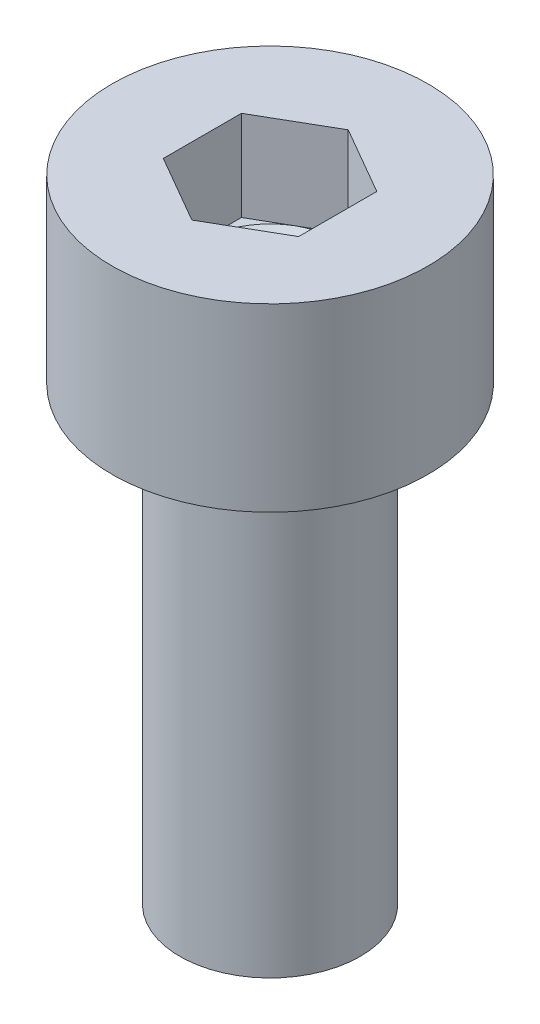
from build123d import *

# Parameters (mm, degrees)
CUT_EXTRUDE1_DEPTH = 2


with BuildPart() as part:
    # Sketch1 → Revolve1 (revolve)
    with BuildSketch(Plane.XY):
        Polygon((0, 0), (3.5, 0), (3.5, -4), (2, -4), (2, -14), (0, -14), align=None)
    revolve(axis=Axis((0, 0, 0), (0, -1, 0)))

    # Sketch2 → Cut-Revolve1 (revolve, cut)
    with BuildSketch(Plane.XY):
        Polygon((1.5, 0), (1.5, -2), (0, -2.866025404), (0, 0), align=None)
    revolve(axis=Axis((0, 0, 0), (0, -1, 0)), mode=Mode.SUBTRACT)

    # Sketch3 → Cut-Extrude1 (cut)
    with BuildSketch(Plane(origin=(0, 0, 0), x_dir=(1, 0, 0), z_dir=(0, 1, 0))):
        Polygon((0, 1.732050808), (-1.5, 0.866025404), (-1.5, -0.866025404), (0, -1.732050808), (1.5, -0.866025404), (1.5, 0.866025404), align=None)
    extrude(amount=-CUT_EXTRUDE1_DEPTH, mode=Mode.SUBTRACT)


solid = part.part
